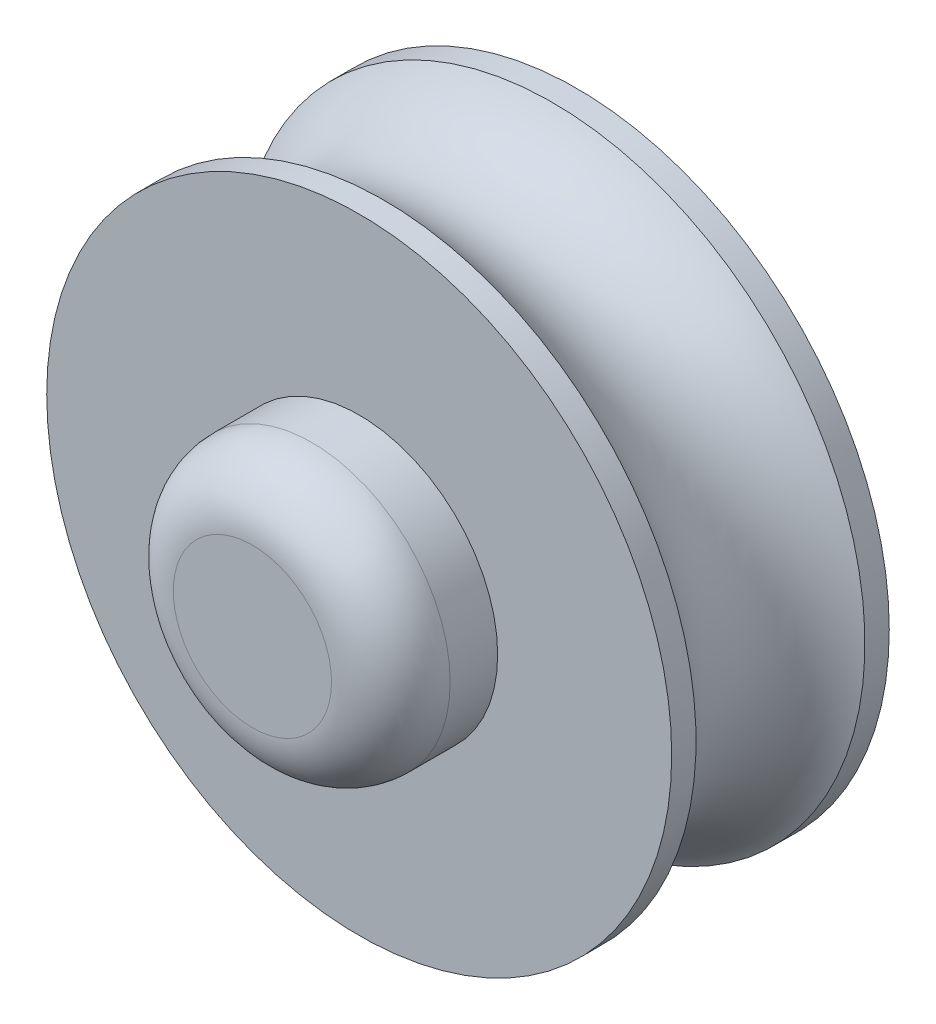
from build123d import *

# Parameters (mm, degrees)
SKETCH_1_R          = 7.9
EXTRUDE_1_DEPTH     = 5.5
SKETCH_2_R          = 3.5
EXTRUDE_2_DEPTH     = 2.7
CUT_EXTRUDE_1_DEPTH = 9.3
FILLET_1_R          = 1.5


with BuildPart() as part:
    # 스케치1 → 보스-돌출1 (new body)
    with BuildSketch(Plane.XY):
        Circle(SKETCH_1_R)
    extrude(amount=EXTRUDE_1_DEPTH)

    # 스케치2 → 보스-돌출2 (add)
    with BuildSketch(Plane.XY.offset(5.5)):
        Circle(SKETCH_2_R)
    extrude(amount=EXTRUDE_2_DEPTH)

    # 스케치6 → 회전1 (revolve)
    with BuildSketch(Plane(origin=(0, 0, 0), x_dir=(0, 0, -1), z_dir=(1, 0, 0))):
        Polygon((0, -7.9), (1.303339378, -3.5), (1.303339378, 0), (0, 0), align=None)
    revolve(axis=Axis((0, 0, 0), (0, 0, -1)))

    # 스케치7 → 컷-돌출1 (cut)
    with BuildSketch(Plane(origin=(0, 0, -1.303339378), x_dir=(-1, 0, 0), z_dir=(0, 0, -1))):
        with BuildLine():
            ThreePointArc((1.6, 0), (0.681175455, 1.447756886), (-1.02, 1.232720568))
            Line((-1.02, 1.232720568), (-1.02, -1.232720568))
            ThreePointArc((-1.02, -1.232720568), (0.681175455, -1.447756886), (1.6, 0))
        make_face()
    extrude(amount=-CUT_EXTRUDE_1_DEPTH, mode=Mode.SUBTRACT)

    # 필렛1
    fillet_1_edges = [part.edges().sort_by_distance(p)[0] for p in [
        (-3.5, 0, 8.2),
    ]]
    fillet(fillet_1_edges, radius=FILLET_1_R)

    # 스케치8 → 컷-회전1 (revolve, cut)
    with BuildSketch(Plane(origin=(0, 0, 0), x_dir=(0, 0, -1), z_dir=(1, 0, 0))):
        with BuildLine():
            Line((-4.885, 7.9), (-0.615, 7.9))
            ThreePointArc((-0.615, 7.9), (-2.75, 6.700682513), (-4.885, 7.9))
        make_face()
    revolve(axis=Axis((0, 0, 0), (0, 0, 1)), mode=Mode.SUBTRACT)


solid = part.part
